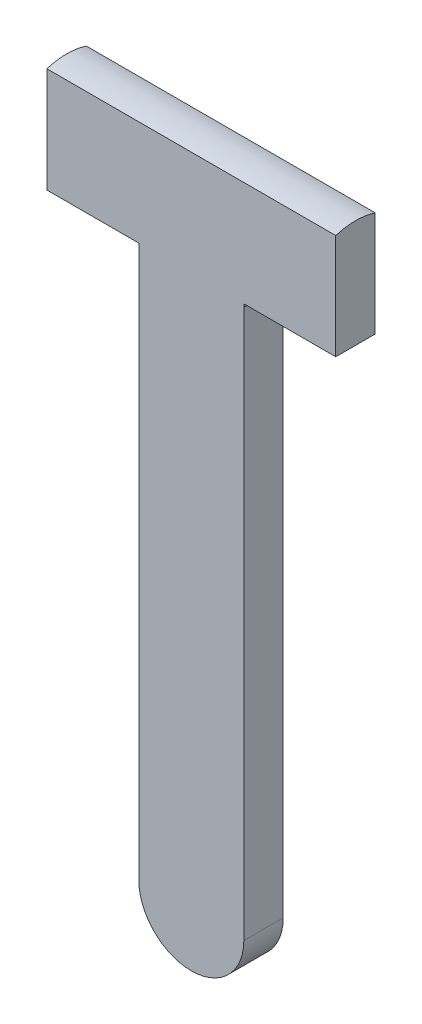
from build123d import *

# Parameters (mm, degrees)
EXTRUSION1_DEPTH = 1.5
EXTRUSION2_DEPTH = 0.1
EXTRUSION3_DEPTH = 11


with BuildPart() as part:
    # Esquisse1 → Extrusion1 (new body)
    with BuildSketch(Plane.XY):
        with BuildLine():
            Line((-5.5, 0), (5.5, 0))
            Line((5.5, 0), (5.5, -4))
            Line((5.5, -4), (2, -4))
            Line((2, -4), (2, -25))
            ThreePointArc((2, -25), (0, -27), (-2, -25))
            Line((-2, -25), (-2, -4))
            Line((-2, -4), (-5.5, -4))
            Line((-5.5, -4), (-5.5, 0))
        make_face()
    extrude(amount=EXTRUSION1_DEPTH)

    # Esquisse2 → Extrusion2 (add)
    with BuildSketch(Plane.XZ.offset(4)):
        with BuildLine():
            Line((-2, 1.5), (-2, 0))
            ThreePointArc((-2, 0), (-2.136000936, 0.75), (-2, 1.5))
        make_face()
        with BuildLine():
            Line((2, 1.5), (2, 0))
            ThreePointArc((2, 0), (2.136000936, 0.75), (2, 1.5))
        make_face()
    extrude(amount=EXTRUSION2_DEPTH)

    # Esquisse3 → Extrusion3 (add)
    with BuildSketch(Plane.ZY.offset(5.5)):
        with BuildLine():
            Line((1.5, 0), (0, 0))
            ThreePointArc((0, 0), (0.75, 0.115151996), (1.5, 0))
        make_face()
    extrude(amount=-EXTRUSION3_DEPTH)


solid = part.part
